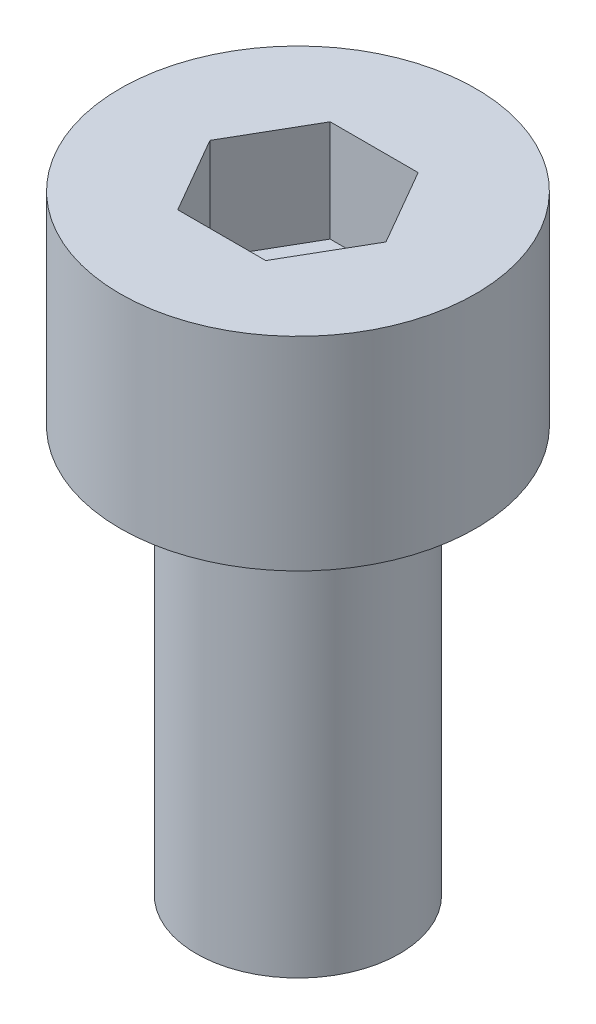
from build123d import *

# Parameters (mm, degrees)
SKETCH_1_R            = 3.5
EXTRUDE_246_DEPTH     = 4
CUT_EXTRUDE_376_DEPTH = 2
SKETCH_3_R            = 2
EXTRUDE_477_DEPTH     = 8


with BuildPart() as part:
    # 草图1 → Extrude 246 (new body)
    with BuildSketch(Plane(origin=(0, 0, 0), x_dir=(1, 0, 0), z_dir=(0, 1, 0))):
        Circle(SKETCH_1_R)
    extrude(amount=EXTRUDE_246_DEPTH)

    # 草图2 → Cut-Extrude 376 (cut)
    with BuildSketch(Plane(origin=(0, 4, 0), x_dir=(1, 0, 0), z_dir=(0, 1, 0))):
        Polygon((1.732050808, 0), (0.866025404, 1.5), (-0.866025404, 1.5), (-1.732050808, 0), (-0.866025404, -1.5), (0.866025404, -1.5), align=None)
    extrude(amount=-CUT_EXTRUDE_376_DEPTH, mode=Mode.SUBTRACT)

    # 草图3 → Extrude 477 (add)
    with BuildSketch(Plane.XZ):
        Circle(SKETCH_3_R)
    extrude(amount=EXTRUDE_477_DEPTH)


solid = part.part
